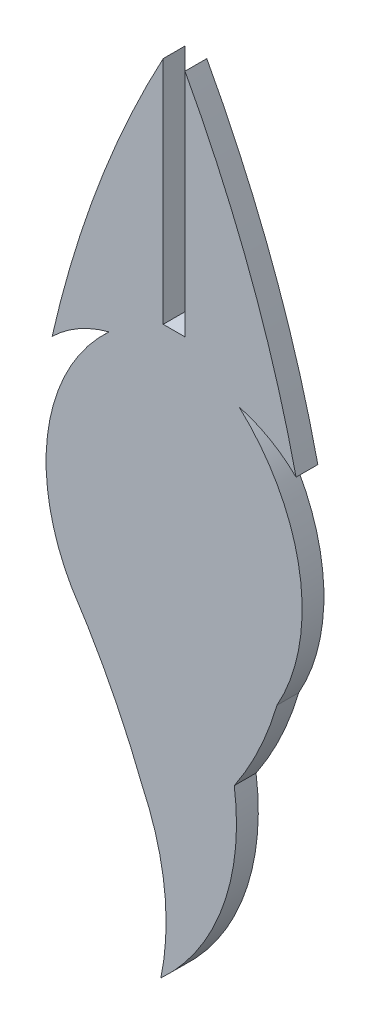
from build123d import *

# Parameters (mm, degrees)
BOSS_EXTRUDE1_DEPTH = 1.524


with BuildPart() as part:
    # Sketch1 → Boss-Extrude1 (new body)
    with BuildSketch(Plane.XY):
        with BuildLine():
            Line((-1.524, -34.676201819), (0, -34.676201819))
            Line((0, -34.676201819), (0, -18.581601914))
            ThreePointArc((0, -18.581601914), (4.586568454, -28.671218755), (7.766480304, -39.288428313))
            ThreePointArc((7.766480304, -39.288428313), (5.922115133, -37.899455621), (3.784796816, -37.026072296))
            ThreePointArc((3.784796816, -37.026072296), (8.024285986, -44.938100791), (6.429295491, -53.771529834))
            ThreePointArc((6.429295491, -53.771529834), (5.182840175, -57.065431108), (3.445514823, -60.128948218))
            ThreePointArc((3.445514823, -60.128948218), (2.639499088, -67.873650649), (-1.687439347, -74.347264855))
            ThreePointArc((-1.687439347, -74.347264855), (-1.444255212, -68.732462045), (-3.001469179, -63.332440397))
            ThreePointArc((-3.001469179, -63.332440397), (-5.223476479, -58.420481145), (-7.953295491, -53.771529834))
            ThreePointArc((-7.953295491, -53.771529834), (-9.548285986, -44.938100791), (-5.308796816, -37.026072296))
            ThreePointArc((-5.308796816, -37.026072296), (-7.446115133, -37.899455621), (-9.290480304, -39.288428313))
            ThreePointArc((-9.290480304, -39.288428313), (-6.110568454, -28.671218755), (-1.524, -18.581601914))
            Line((-1.524, -18.581601914), (-1.524, -34.676201819))
        make_face()
    extrude(amount=BOSS_EXTRUDE1_DEPTH)


solid = part.part
